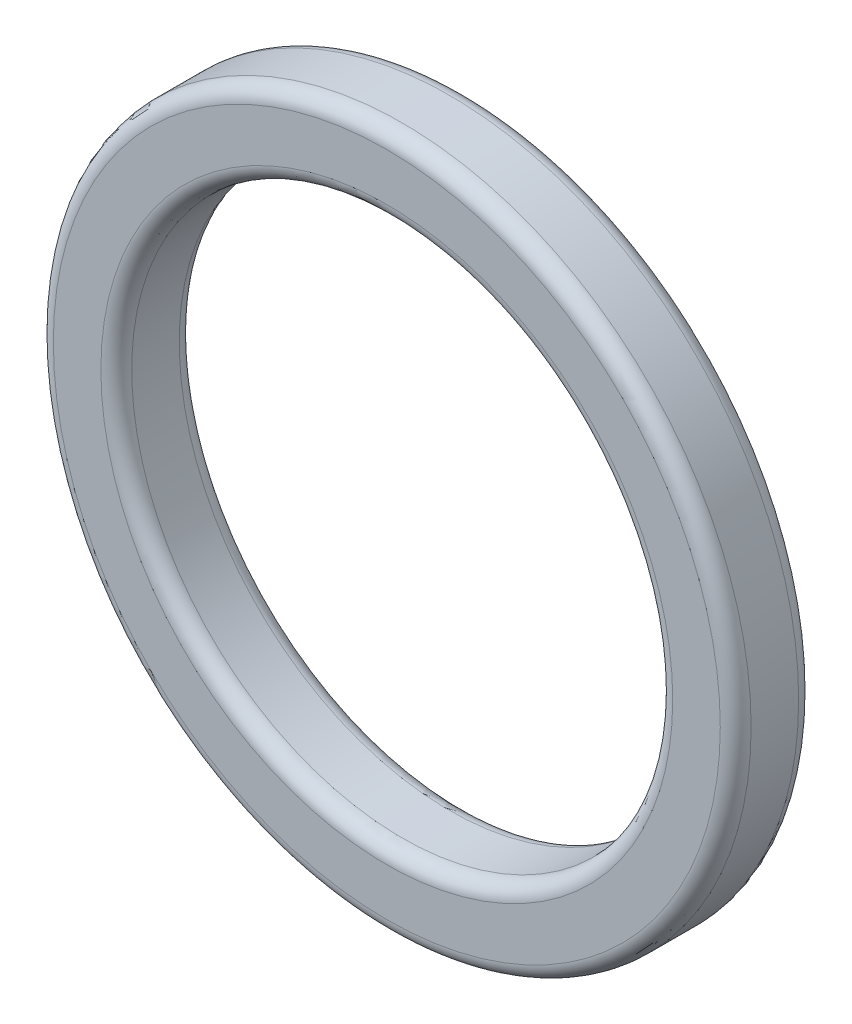
from build123d import *

# Parameters (mm, degrees)
SKETCH1_R           = 22.612840435
SKETCH1_R_2         = 17.532840435
EXTRUDE_THIN1_DEPTH = 5.08
FILLET1_R           = 1


with BuildPart() as part:
    # Sketch1 → Extrude-Thin1 (new body)
    with BuildSketch(Plane.XY):
        with Locations((39.784875199, 9.634635023)):
            Circle(SKETCH1_R)
        with Locations((39.784875199, 9.634635023)):
            Circle(SKETCH1_R_2, mode=Mode.SUBTRACT)
    extrude(amount=EXTRUDE_THIN1_DEPTH)

    # Fillet1
    fillet1_edges = [part.edges().sort_by_distance(p)[0] for p in [
        (17.172034764, 9.634635023, 0),
        (17.172034764, 9.634635023, 5.08),
        (22.252034764, 9.634635023, 0),
        (22.252034764, 9.634635023, 5.08),
    ]]
    fillet(fillet1_edges, radius=FILLET1_R)


solid = part.part
